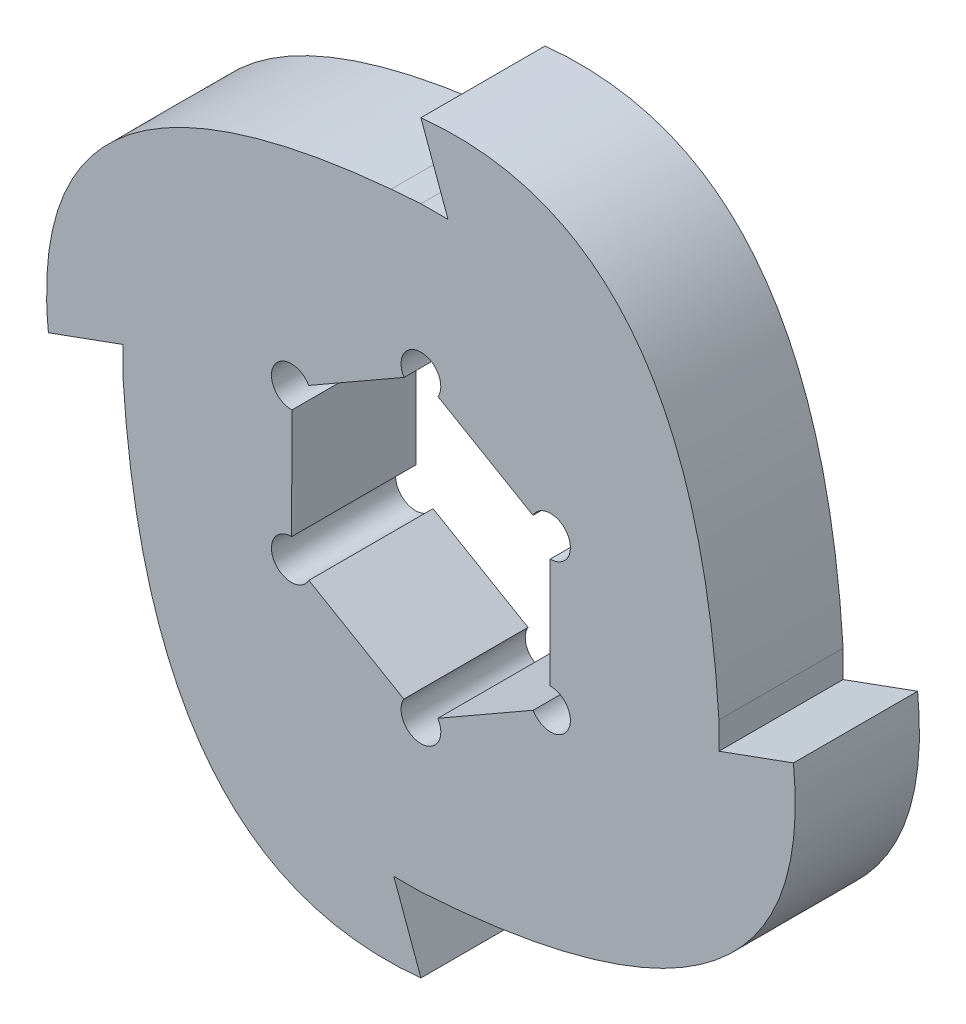
from build123d import *

# Parameters (mm, degrees)
BOSS_EXTRUDE2_DEPTH = 6.35


with BuildPart() as part:
    # Sketch1 → Boss-Extrude2 (new body)
    with BuildSketch(Plane.XY):
        with BuildLine():
            Line((-19.05, 0), (-15.24, 1.386726593))
            Line((-15.24, 1.386726593), (-15.24, 0))
            add(Edge.make_bspline(
                [(-15.24, 0), (-13.932101613, -20.478619227), (0, -19.05)],
                knots=[0, 0, 0, 0.635745988, 0.635745988, 0.635745988], degree=2))
            Line((0, -19.05), (-1.386726593, -15.24))
            Line((-1.386726593, -15.24), (0, -15.24))
            add(Edge.make_bspline(
                [(0, -15.24), (20.478619227, -13.932101613), (19.05, 0)],
                knots=[0, 0, 0, 0.635745988, 0.635745988, 0.635745988], degree=2))
            Line((19.05, 0), (15.24, -1.386726593))
            Line((15.24, -1.386726593), (15.24, 0))
            add(Edge.make_bspline(
                [(15.24, 0), (13.932101613, 20.478619227), (0, 19.05)],
                knots=[0, 0, 0, 0.635745988, 0.635745988, 0.635745988], degree=2))
            Line((0, 19.05), (1.386726593, 15.24))
            Line((1.386726593, 15.24), (0, 15.24))
            add(Edge.make_bspline(
                [(0, 15.24), (-20.478619227, 13.932101613), (-19.05, 0)],
                knots=[0, 0, 0, 0.635745988, 0.635745988, 0.635745988], degree=2))
        make_face()
        with BuildLine():
            Line((6.594985068, -2.811017562), (6.613082013, 2.810596285))
            ThreePointArc((6.613082013, 2.810596285), (7.502999025, 4.342309614), (5.731905154, 4.305915826))
            Line((5.731905154, 4.305915826), (0.872493224, 7.132395163))
            ThreePointArc((0.872493224, 7.132395163), (-0.009050924, 8.668942567), (-0.863079915, 7.116933388))
            Line((-0.863079915, 7.116933388), (-5.740588789, 4.321798878))
            ThreePointArc((-5.740588789, 4.321798878), (-7.512049949, 4.326632954), (-6.594985068, 2.811017562))
            Line((-6.594985068, 2.811017562), (-6.613082013, -2.810596285))
            ThreePointArc((-6.613082013, -2.810596285), (-7.502999025, -4.342309614), (-5.731905154, -4.305915826))
            Line((-5.731905154, -4.305915826), (-0.872493224, -7.132395163))
            ThreePointArc((-0.872493224, -7.132395163), (0.009050924, -8.668942567), (0.863079915, -7.116933388))
            Line((0.863079915, -7.116933388), (5.740588789, -4.321798878))
            ThreePointArc((5.740588789, -4.321798878), (7.512049949, -4.326632954), (6.594985068, -2.811017562))
        make_face(mode=Mode.SUBTRACT)
    extrude(amount=BOSS_EXTRUDE2_DEPTH)


solid = part.part
